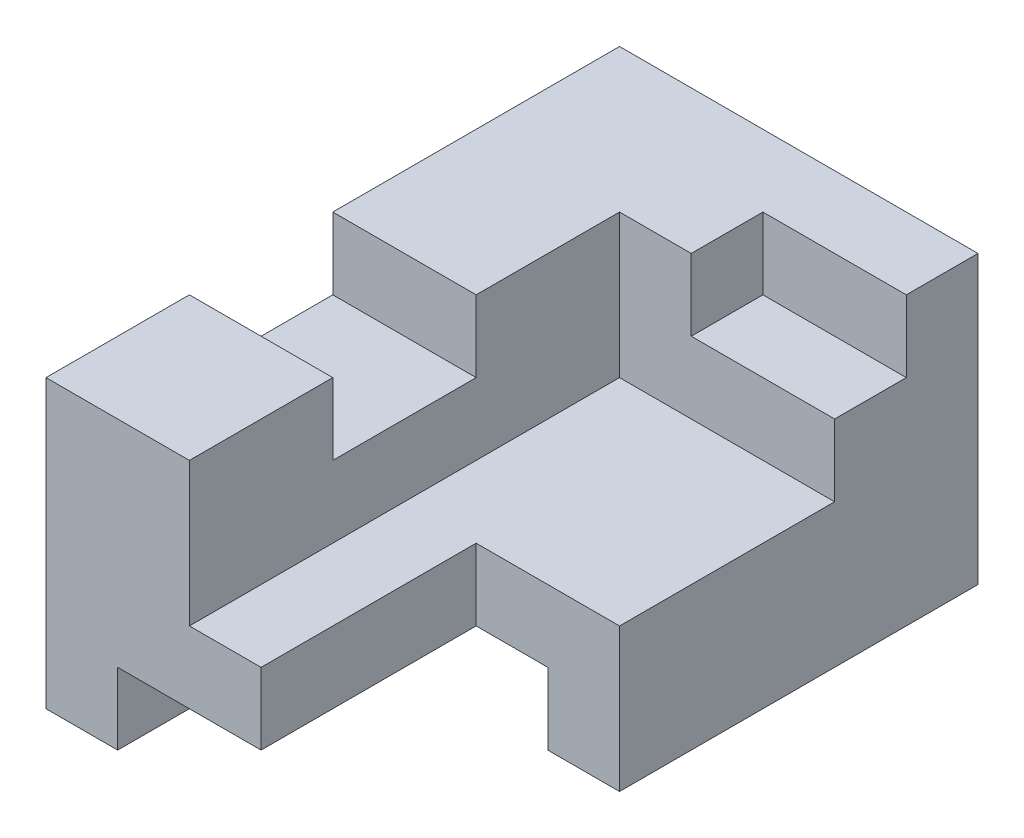
from build123d import *

# Parameters (mm, degrees)
SKETCH1_W           = 5
SKETCH1_H           = 4
BOSS_EXTRUDE1_DEPTH = 8
SKETCH2_W           = 2
SKETCH2_H           = 2
SKETCH2_H_2         = 1
CUT_EXTRUDE1_DEPTH  = 1
SKETCH4_W           = 6.112752517
SKETCH4_H           = 2
CUT_EXTRUDE2_DEPTH  = 3
SKETCH5_W           = 2
SKETCH5_H           = 3
CUT_EXTRUDE3_DEPTH  = 3
SKETCH6_W           = 3
SKETCH6_H           = 1
CUT_EXTRUDE5_DEPTH  = 9


with BuildPart() as part:
    # Sketch1 → Boss-Extrude1 (new body)
    with BuildSketch(Plane.XY):
        Rectangle(SKETCH1_W, SKETCH1_H)
    extrude(amount=BOSS_EXTRUDE1_DEPTH)

    # Sketch2 → Cut-Extrude1 (cut)
    with BuildSketch(Plane(origin=(0, 2, 0), x_dir=(1, 0, 0), z_dir=(0, 1, 0))):
        with Locations((-1.5, -5)):
            Rectangle(SKETCH2_W, SKETCH2_H)
        with Locations((1.5, -1.5)):
            Rectangle(SKETCH2_W, SKETCH2_H_2)
    extrude(amount=-CUT_EXTRUDE1_DEPTH, mode=Mode.SUBTRACT)

    # Sketch4 → Cut-Extrude2 (cut)
    with BuildSketch(Plane(origin=(2.5, 0, 0), x_dir=(0, 0, -1), z_dir=(1, 0, 0))):
        with Locations((-5.056376259, 1)):
            Rectangle(SKETCH4_W, SKETCH4_H)
    extrude(amount=-CUT_EXTRUDE2_DEPTH, mode=Mode.SUBTRACT)

    # Sketch5 → Cut-Extrude3 (cut)
    with BuildSketch(Plane(origin=(0, 0, 0), x_dir=(1, 0, 0), z_dir=(0, 1, 0))):
        with Locations((1.5, -6.5)):
            Rectangle(SKETCH5_W, SKETCH5_H)
    extrude(amount=-CUT_EXTRUDE3_DEPTH, mode=Mode.SUBTRACT)

    # Sketch6 → Cut-Extrude5 (cut, through all)
    with BuildSketch(Plane.XY.offset(8)):
        with Locations((0, -1.5)):
            Rectangle(SKETCH6_W, SKETCH6_H)
    extrude(amount=-CUT_EXTRUDE5_DEPTH, mode=Mode.SUBTRACT)


solid = part.part
